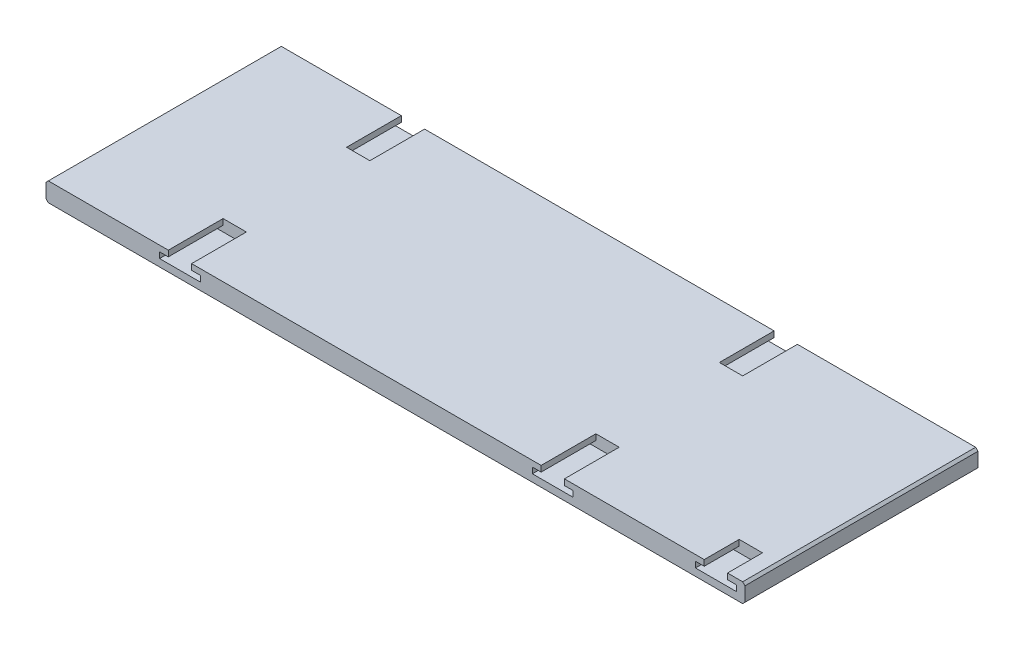
from build123d import *

# Parameters (mm, degrees)
ESQUISSE1_W             = 600
ESQUISSE1_H             = 16.28
BOSS_EXTRU_1_DEPTH      = 100
CHANFREIN1_SIZE         = 2
ENL_V_START             = -53
ENL_V_MAT_EXTRU_1_DEPTH = 48
ENL_V_START_2           = 53
ENL_V_MAT_EXTRU_2_DEPTH = 48
ENL_V_START_3           = 100
ENL_V_MAT_EXTRU_4_DEPTH = 30


with BuildPart() as part:
    # Esquisse1 → Boss.-Extru.1 (new body, symmetric)
    with BuildSketch(Plane.XY):
        with Locations((300, 8.14)):
            Rectangle(ESQUISSE1_W, ESQUISSE1_H)
    extrude(amount=BOSS_EXTRU_1_DEPTH, both=True)

    # Chanfrein1
    chanfrein1_edges = [part.edges().sort_by_distance(p)[0] for p in [
        (600, 16.28, 0),
        (600, 0, 0),
        (0, 0, 0),
        (0, 16.28, 0),
    ]]
    chamfer(chanfrein1_edges, length=CHANFREIN1_SIZE)

    # Esquisse1_4 → Enl_v. mat.-Extru.1 (cut, through all)
    with BuildSketch(Plane.XY.offset(ENL_V_START)):
        Polygon((105, 16.28), (125, 16.28), (125, 11.28), (132.5, 11.28), (132.5, 6.28), (97.5, 6.28), (97.5, 11.28), (105, 11.28), align=None)
        Polygon((425, 16.28), (445, 16.28), (445, 11.28), (452.5, 11.28), (452.5, 6.28), (417.5, 6.28), (417.5, 11.28), (425, 11.28), align=None)
    extrude(amount=-ENL_V_MAT_EXTRU_1_DEPTH, mode=Mode.SUBTRACT)

    # Esquisse1_5 → Enl_v. mat.-Extru.2 (cut, through all)
    with BuildSketch(Plane.XY.offset(ENL_V_START_2)):
        Polygon((105, 16.28), (125, 16.28), (125, 11.28), (132.5, 11.28), (132.5, 6.28), (97.5, 6.28), (97.5, 11.28), (105, 11.28), align=None)
        Polygon((425, 16.28), (445, 16.28), (445, 11.28), (452.5, 11.28), (452.5, 6.28), (417.5, 6.28), (417.5, 11.28), (425, 11.28), align=None)
    extrude(amount=ENL_V_MAT_EXTRU_2_DEPTH, mode=Mode.SUBTRACT)

    # Esquisse1_9 → Enl_v. mat.-Extru.4 (cut)
    with BuildSketch(Plane.XY.offset(ENL_V_START_3)):
        Polygon((585, 11.28), (585, 16.28), (565, 16.28), (565, 11.28), (557.5, 11.28), (557.5, 6.28), (592.5, 6.28), (592.5, 11.28), align=None)
    extrude(amount=-ENL_V_MAT_EXTRU_4_DEPTH, mode=Mode.SUBTRACT)


solid = part.part
